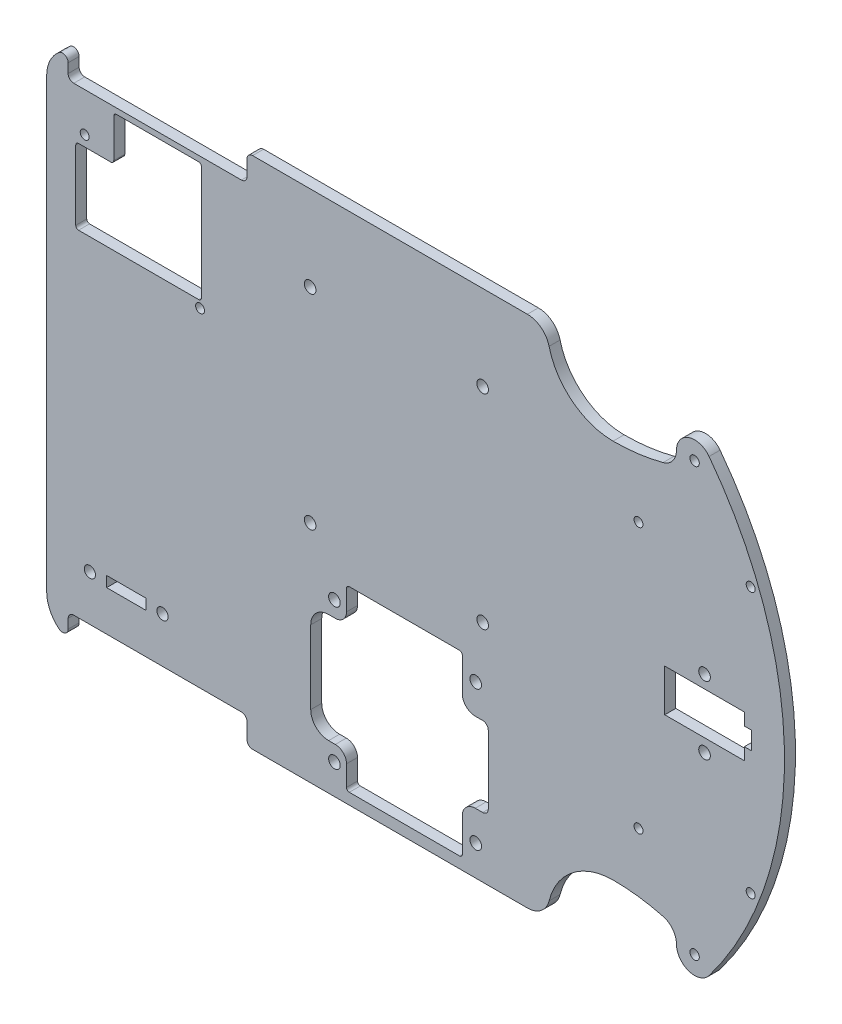
from build123d import *

# Parameters (mm, degrees)
CROQUIS1_W                = 209.55
CROQUIS1_H                = 146.05
SALIENTE_EXTRUIR1_DEPTH   = 3.1242
CROQUIS2_R                = 1.3335
CORTAR_EXTRUIR1_DEPTH     = 128.750584639
CROQUIS9_R                = 1.27
CORTAR_EXTRUIR6_DEPTH     = 128.750584639
CORTAR_EXTRUIR2_DEPTH     = 128.750584639
CROQUIS5_R                = 1.651
DRIVER_DEPTH              = 128.750584639
CROQUIS6_R                = 1.651
RASPI_DEPTH               = 128.750584639
CROQUIS8_R                = 1.27
DIFERENCIAL_TRASERO_DEPTH = 128.750584639
CROQUIS7_R                = 1.5875
CROQUIS7_W                = 11.1125
CROQUIS7_H                = 2.9972
CORTAR_EXTRUIR7_DEPTH     = 128.750584639
CROQUIS10_R               = 1.651
CROQUIS10_W               = 22.606
CROQUIS10_H               = 11.9888
CORTAR_EXTRUIR10_DEPTH    = 128.750584639
CORTAR_EXTRUIR11_DEPTH    = 128.750584639


with BuildPart() as part:
    # Croquis1 → Saliente-Extruir1 (new body)
    with BuildSketch(Plane.XY):
        Rectangle(CROQUIS1_W, CROQUIS1_H)
    extrude(amount=SALIENTE_EXTRUIR1_DEPTH)

    # Croquis2 → Cortar-Extruir1 (cut, through all)
    with BuildSketch(Plane.XY.offset(3.1242)):
        with BuildLine():
            ThreePointArc((80.5799125, 60.7314), (79.928852882, 61.877042778), (78.6114125, 61.904002767))
            Line((78.6114125, 61.904002767), (78.6114125, 59.558797233))
            ThreePointArc((78.6114125, 59.558797233), (79.928852882, 59.585757222), (80.5799125, 60.7314))
        make_face()
        with BuildLine():
            Line((78.6114125, 59.558797233), (78.6114125, 61.904002767))
            ThreePointArc((78.6114125, 61.904002767), (77.9129125, 60.7314), (78.6114125, 59.558797233))
        make_face()
        with Locations(Location((79.2464125, -60.7314, 0), (0, 0, 180))):
            Circle(CROQUIS2_R)
    extrude(amount=-CORTAR_EXTRUIR1_DEPTH, mode=Mode.SUBTRACT)

    # Croquis9 → Cortar-Extruir6 (cut, through all)
    with BuildSketch(Plane.XY.offset(3.1242)):
        with Locations((63.3206125, 37.6809)):
            Circle(CROQUIS9_R)
        with Locations((95.1722125, 37.6809)):
            Circle(CROQUIS9_R)
        with Locations(Location((95.1722125, -37.6809, 0), (0, 0, 180))):
            Circle(CROQUIS9_R)
        with Locations(Location((63.3206125, -37.6809, 0), (0, 0, 180))):
            Circle(CROQUIS9_R)
    extrude(amount=-CORTAR_EXTRUIR6_DEPTH, mode=Mode.SUBTRACT)

    # Croquis3 → Cortar-Extruir2 (cut, through all)
    with BuildSketch(Plane.XY.offset(3.1242)):
        with BuildLine():
            Line((38.1, 67.507041999), (38.1, 73.025))
            Line((38.1, 73.025), (31.75, 73.025))
            ThreePointArc((31.75, 73.025), (35.663372801, 71.675801268), (37.913779422, 68.201539629))
            ThreePointArc((37.913779422, 68.201539629), (38.003556568, 67.853397075), (38.1, 67.507041999))
        make_face()
        with BuildLine():
            Line((74.0870375, 73.025), (38.1, 73.025))
            Line((38.1, 73.025), (38.1, 67.507041999))
            ThreePointArc((38.1, 67.507041999), (44.836488972, 57.735545708), (56.09351875, 53.975))
            ThreePointArc((56.09351875, 53.975), (63.258442282, 54.43812298), (70.304123502, 55.81978439))
            ThreePointArc((70.304123502, 55.81978439), (73.03168636, 57.631625564), (74.0870375, 60.7314))
            Line((74.0870375, 60.7314), (74.0870375, 73.025))
        make_face()
        with BuildLine():
            Line((104.775, 73.025), (74.0870375, 73.025))
            Line((74.0870375, 73.025), (74.0870375, 60.7314))
            ThreePointArc((74.0870375, 60.7314), (77.605786537, 65.622974066), (83.362384549, 63.842336271))
            ThreePointArc((83.362384549, 63.842336271), (99.279214777, 33.668769191), (104.775, 5.82e-07))
            Line((104.775, 5.82e-07), (104.775, 73.025))
        make_face()
        with BuildLine():
            Line((104.775, -73.025), (104.775, 5.82e-07))
            ThreePointArc((104.775, 5.82e-07), (99.279214962, -33.668768639), (83.362384549, -63.842336271))
            ThreePointArc((83.362384549, -63.842336271), (77.605786537, -65.622974066), (74.0870375, -60.7314))
            Line((74.0870375, -60.7314), (74.0870375, -73.025))
            Line((74.0870375, -73.025), (104.775, -73.025))
        make_face()
        with BuildLine():
            Line((74.0870375, -73.025), (74.0870375, -60.7314))
            ThreePointArc((74.0870375, -60.7314), (73.03168636, -57.631625564), (70.304123502, -55.81978439))
            ThreePointArc((70.304123502, -55.81978439), (63.258442282, -54.43812298), (56.09351875, -53.975))
            ThreePointArc((56.09351875, -53.975), (44.836488972, -57.735545708), (38.1, -67.507041999))
            Line((38.1, -67.507041999), (38.1, -73.025))
            Line((38.1, -73.025), (74.0870375, -73.025))
        make_face()
        with BuildLine():
            ThreePointArc((37.913779422, -68.201539629), (35.663372801, -71.675801268), (31.75, -73.025))
            Line((31.75, -73.025), (38.1, -73.025))
            Line((38.1, -73.025), (38.1, -67.507041999))
            ThreePointArc((38.1, -67.507041999), (38.003556568, -67.853397075), (37.913779422, -68.201539629))
        make_face()
        with BuildLine():
            ThreePointArc((-104.775, 63.5), (-101.985192091, 70.235192091), (-95.25, 73.025))
            Line((-95.25, 73.025), (-104.775, 73.025))
            Line((-104.775, 73.025), (-104.775, 63.5))
        make_face()
        with BuildLine():
            Line((-104.775, -73.025), (-95.25, -73.025))
            ThreePointArc((-95.25, -73.025), (-101.985192091, -70.235192091), (-104.775, -63.5))
            Line((-104.775, -63.5), (-104.775, -73.025))
        make_face()
    extrude(amount=-CORTAR_EXTRUIR2_DEPTH, mode=Mode.SUBTRACT)

    # Croquis5 → Driver (cut, through all)
    with BuildSketch(Plane.XY.offset(3.1242)):
        with BuildLine():
            Line((12.47775, -19.2786), (-18.82775, -19.2786))
            ThreePointArc((-18.82775, -19.2786), (-19.389016008, -19.511083992), (-19.6215, -20.07235))
            Line((-19.6215, -20.07235), (-19.6215, -25.8826))
            ThreePointArc((-19.6215, -25.8826), (-20.55143597, -28.12766403), (-22.7965, -29.0576))
            Line((-22.7965, -29.0576), (-24.7015, -29.0576))
            ThreePointArc((-24.7015, -29.0576), (-28.293602448, -30.545497552), (-29.7815, -34.1376))
            Line((-29.7815, -34.1376), (-29.7815, -54.991))
            ThreePointArc((-29.7815, -54.991), (-28.293602448, -58.583102448), (-24.7015, -60.071))
            Line((-24.7015, -60.071), (-22.7965, -60.071))
            ThreePointArc((-22.7965, -60.071), (-20.55143597, -61.00093597), (-19.6215, -63.246))
            Line((-19.6215, -63.246), (-19.6215, -69.05625))
            ThreePointArc((-19.6215, -69.05625), (-19.389016008, -69.617516008), (-18.82775, -69.85))
            Line((-18.82775, -69.85), (12.47775, -69.85))
            ThreePointArc((12.47775, -69.85), (13.039016008, -69.617516008), (13.2715, -69.05625))
            Line((13.2715, -69.05625), (13.2715, -59.563))
            ThreePointArc((13.2715, -59.563), (14.350225725, -56.958725725), (16.9545, -55.88))
            Line((16.9545, -55.88), (19.05, -55.88))
            ThreePointArc((19.05, -55.88), (20.172532015, -55.415032015), (20.6375, -54.2925))
            Line((20.6375, -54.2925), (20.6375, -34.8361))
            ThreePointArc((20.6375, -34.8361), (20.172532015, -33.713567985), (19.05, -33.2486))
            Line((19.05, -33.2486), (16.9545, -33.2486))
            ThreePointArc((16.9545, -33.2486), (14.350225725, -32.169874275), (13.2715, -29.5656))
            Line((13.2715, -29.5656), (13.2715, -20.07235))
            ThreePointArc((13.2715, -20.07235), (13.039016008, -19.511083992), (12.47775, -19.2786))
        make_face()
        with Locations((17.0815, -24.7396)):
            Circle(CROQUIS5_R)
        with Locations((-23.0505, -24.6126)):
            Circle(CROQUIS5_R)
        with Locations(Location((17.0815, -64.389, 0), (0, 0, 180))):
            Circle(CROQUIS5_R)
        with Locations(Location((-23.0505, -64.516, 0), (0, 0, 180))):
            Circle(CROQUIS5_R)
    extrude(amount=-DRIVER_DEPTH, mode=Mode.SUBTRACT)

    # Croquis6 → RasPi (cut, through all)
    with BuildSketch(Plane.XY.offset(3.1242)):
        with Locations((-29.95, 48.8814)):
            Circle(CROQUIS6_R)
        with Locations((19.05, 48.8814)):
            Circle(CROQUIS6_R)
        with Locations((19.05, -9.1186)):
            Circle(CROQUIS6_R)
        with Locations((-29.95, -9.1186)):
            Circle(CROQUIS6_R)
    extrude(amount=-RASPI_DEPTH, mode=Mode.SUBTRACT)

    # Croquis8 → Diferencial trasero (cut, through all)
    with BuildSketch(Plane.XY.offset(3.1242)):
        with Locations((-93.98, 54.3306)):
            Circle(CROQUIS8_R)
        with Locations((-61.214, 28.0162)):
            Circle(CROQUIS8_R)
    extrude(amount=-DIFERENCIAL_TRASERO_DEPTH, mode=Mode.SUBTRACT)

    # Croquis7 → Cortar-Extruir7 (cut, through all)
    with BuildSketch(Plane.XY.offset(3.1242)):
        with Locations((-92.508859415, -52.4764)):
            Circle(CROQUIS7_R)
        with Locations((-71.871359415, -52.4764)):
            Circle(CROQUIS7_R)
        with Locations((-82.190109415, -52.4764)):
            Rectangle(CROQUIS7_W, CROQUIS7_H)
    extrude(amount=-CORTAR_EXTRUIR7_DEPTH, mode=Mode.SUBTRACT)

    # Croquis10 → Cortar-Extruir10 (cut, through all)
    with BuildSketch(Plane.XY.offset(3.1242)):
        with Locations((82.0674, 9.652)):
            Circle(CROQUIS10_R)
        with Locations((82.0674, 0)):
            Rectangle(CROQUIS10_W, CROQUIS10_H)
        with Locations((82.0674, -9.652)):
            Circle(CROQUIS10_R)
        Polygon((93.3704, -1.966579717), (93.3704, -2.54), (95.4024, -2.54), (95.4024, 2.54), (93.3704, 2.54), align=None)
    extrude(amount=-CORTAR_EXTRUIR10_DEPTH, mode=Mode.SUBTRACT)

    # Croquis11 → Cortar-Extruir11 (cut, through all)
    with BuildSketch(Plane.XY.offset(3.1242)):
        with BuildLine():
            Line((-61.62675, 63.8302), (-84.93125, 63.8302))
            ThreePointArc((-84.93125, 63.8302), (-85.492516008, 63.597716008), (-85.725, 63.03645))
            Line((-85.725, 63.03645), (-85.725, 52.0827))
            ThreePointArc((-85.725, 52.0827), (-85.957483992, 51.521433992), (-86.51875, 51.28895))
            Line((-86.51875, 51.28895), (-95.72625, 51.28895))
            ThreePointArc((-95.72625, 51.28895), (-96.287516008, 51.056466008), (-96.52, 50.4952))
            Line((-96.52, 50.4952), (-96.52, 30.7467))
            ThreePointArc((-96.52, 30.7467), (-96.287516008, 30.185433992), (-95.72625, 29.95295))
            Line((-95.72625, 29.95295), (-61.62675, 29.95295))
            ThreePointArc((-61.62675, 29.95295), (-61.065483992, 30.185433992), (-60.833, 30.7467))
            Line((-60.833, 30.7467), (-60.833, 63.03645))
            ThreePointArc((-60.833, 63.03645), (-61.065483992, 63.597716008), (-61.62675, 63.8302))
        make_face()
        with BuildLine():
            ThreePointArc((-95.25, 73.025), (-98.445006556, 72.473157644), (-101.2698, 70.881573881))
            ThreePointArc((-101.2698, 70.881573881), (-99.585538364, 71.085343471), (-98.679, 69.651311567))
            Line((-98.679, 69.651311567), (-98.679, 67.0052))
            ThreePointArc((-98.679, 67.0052), (-98.214032015, 65.882667985), (-97.0915, 65.4177))
            Line((-97.0915, 65.4177), (-49.4665, 65.4177))
            ThreePointArc((-49.4665, 65.4177), (-48.343967985, 65.882667985), (-47.879, 67.0052))
            Line((-47.879, 67.0052), (-47.879, 71.4375))
            ThreePointArc((-47.879, 71.4375), (-47.414032015, 72.560032015), (-46.2915, 73.025))
            Line((-46.2915, 73.025), (-95.25, 73.025))
        make_face()
        with BuildLine():
            ThreePointArc((-98.679, -69.651311567), (-99.585538364, -71.085343471), (-101.2698, -70.881573881))
            ThreePointArc((-101.2698, -70.881573881), (-98.445006556, -72.473157644), (-95.25, -73.025))
            Line((-95.25, -73.025), (-46.2915, -73.025))
            ThreePointArc((-46.2915, -73.025), (-47.414032015, -72.560032015), (-47.879, -71.4375))
            Line((-47.879, -71.4375), (-47.879, -67.0052))
            ThreePointArc((-47.879, -67.0052), (-48.343967985, -65.882667985), (-49.4665, -65.4177))
            Line((-49.4665, -65.4177), (-97.0915, -65.4177))
            ThreePointArc((-97.0915, -65.4177), (-98.214032015, -65.882667985), (-98.679, -67.0052))
            Line((-98.679, -67.0052), (-98.679, -69.651311567))
        make_face()
    extrude(amount=-CORTAR_EXTRUIR11_DEPTH, mode=Mode.SUBTRACT)


solid = part.part
